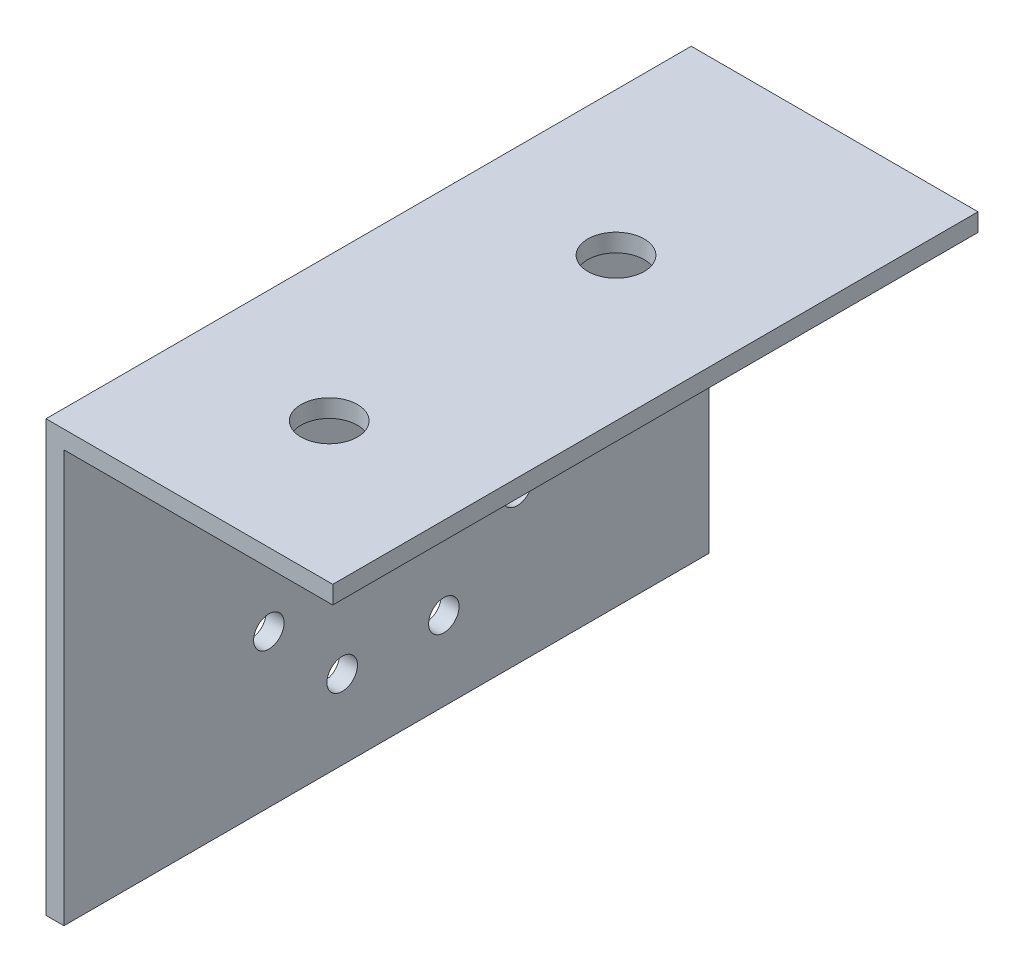
from build123d import *

# Parameters (mm, degrees)
BOSS_EXTRUDE1_DEPTH = 57.15
SKETCH3_R           = 1.35
CUT_EXTRUDE1_DEPTH  = 2.5875
SKETCH2_R           = 2.5
CUT_EXTRUDE2_DEPTH  = 2.5875


with BuildPart() as part:
    # Sketch1 → Boss-Extrude1 (new body)
    with BuildSketch(Plane.XY):
        Polygon((-0.251653512, 27.381273354), (-25.651653512, 27.381273354), (-25.651653512, -10.718726646), (-24.064153512, -10.718726646), (-24.064153512, 25.793773354), (-0.251653512, 25.793773354), align=None)
    extrude(amount=BOSS_EXTRUDE1_DEPTH)

    # Sketch3 → Cut-Extrude1 (cut, through all)
    with BuildSketch(Plane(origin=(-24.064153512, 0, 0), x_dir=(0, 0, -1), z_dir=(1, 0, 0))):
        with Locations((-32.5, 18.281273354)):
            Circle(SKETCH3_R)
        with Locations((-23.5, 18.281273354)):
            Circle(SKETCH3_R)
        with Locations((-17, 11.781273354)):
            Circle(SKETCH3_R)
        with Locations((-17, 2.781273354)):
            Circle(SKETCH3_R)
        with Locations((-23.5, -3.718726646)):
            Circle(SKETCH3_R)
        with Locations((-32.5, -3.718726646)):
            Circle(SKETCH3_R)
        with Locations((-39, 2.781273354)):
            Circle(SKETCH3_R)
        with Locations((-39, 11.781273354)):
            Circle(SKETCH3_R)
    extrude(amount=-CUT_EXTRUDE1_DEPTH, mode=Mode.SUBTRACT)

    # Sketch2 → Cut-Extrude2 (cut, through all)
    with BuildSketch(Plane.XZ.offset(-25.793773354)):
        with Locations((-12.951653512, 44.762965599)):
            Circle(SKETCH2_R)
        with Locations((-12.951653512, 19.362965599)):
            Circle(SKETCH2_R)
    extrude(amount=-CUT_EXTRUDE2_DEPTH, mode=Mode.SUBTRACT)


solid = part.part
